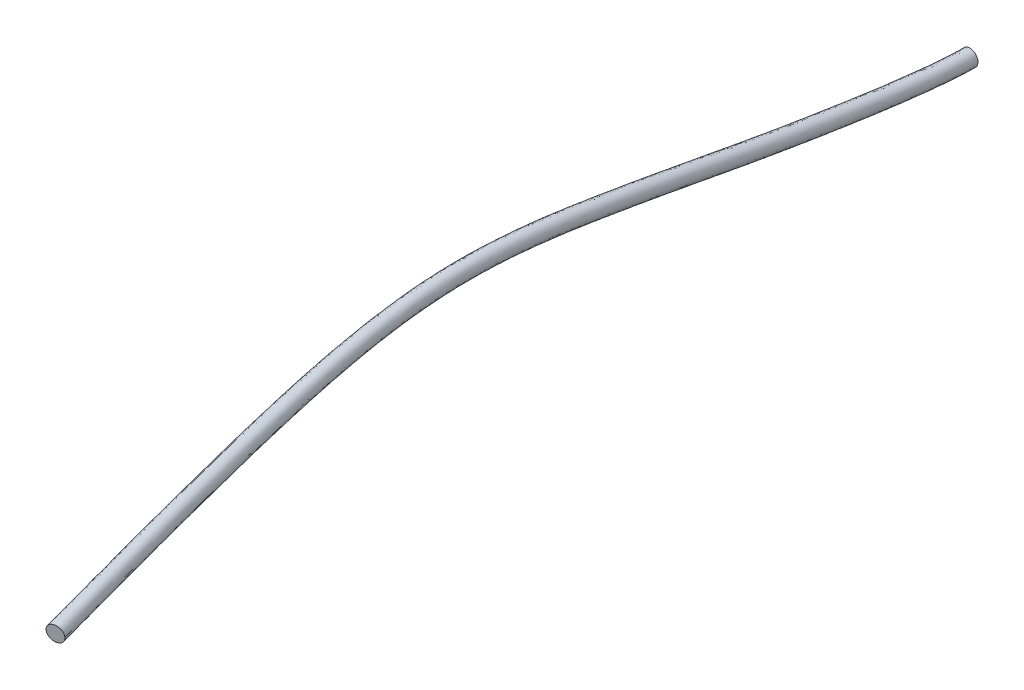
from build123d import *

# Parameters (mm, degrees)
SKETCH1_R = 1.15


with BuildPart() as part:
    # Sweep1: sweep along a curve in space
    with BuildLine() as sweep1_path:
        add(Edge.make_bspline(
            [(0, 0, 0), (0, 0, 5.554280497), (-1.761230112, 1.932071992, 28.783862123), (-2.809917169, 4.330321487, 43.933903769), (-5.189165294, 6.755968288, 74.494593623), (-1.865830616, 2.790133432, 99.905174869), (4.606532714, -1.330605968, 134.515990323)],
            knots=[0, 0, 0, 0, 0.255984711, 0.525951588, 0.698297396, 1, 1, 1, 1], degree=3))
    # Sketch1 → Sweep1 (sweep)
    with BuildSketch(Plane.XY):
        Circle(SKETCH1_R)
    sweep(path=sweep1_path.line)


solid = part.part
